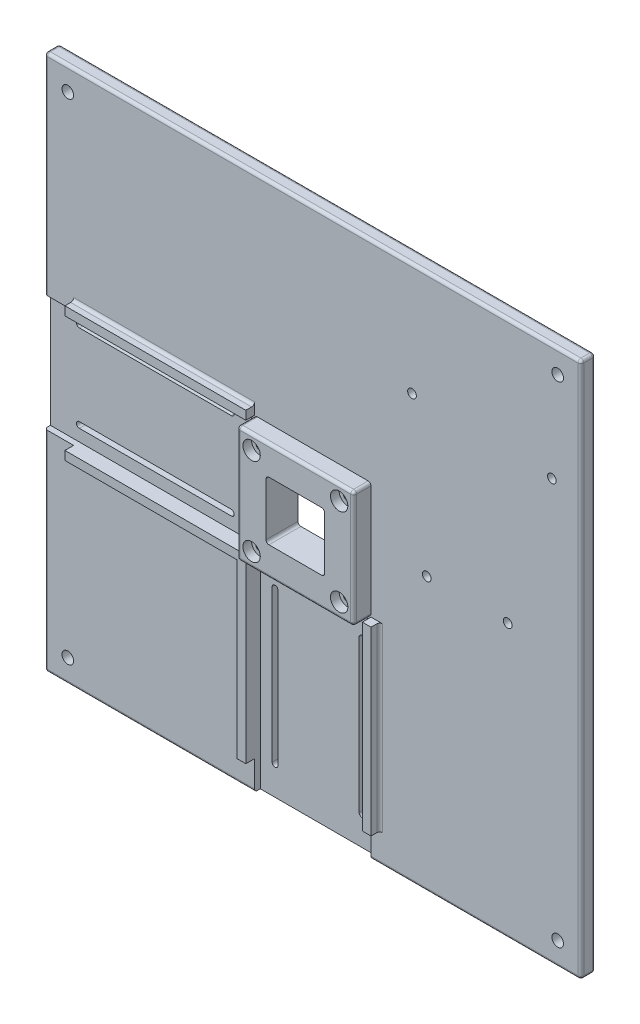
from build123d import *

# Parameters (mm, degrees)
ESQUISSE1_W                  = 185
ESQUISSE1_H                  = 185
BOSS_EXTRU_1_DEPTH           = 5
CONG_1_R                     = 1
ENL_V_MAT_EXTRU_4_REACH      = 7
ESQUISSE9_R                  = 2
ESQUISSE4_R                  = 1.6
ESQUISSE4_W                  = 20.2
ESQUISSE4_H                  = 20.2
ENL_V_MAT_EXTRU_5_DEPTH      = 1
ENL_V_MAT_EXTRU_5_DEPTH_BACK = 6
ESQUISSE11_W                 = 40.2
ESQUISSE11_H                 = 40.2
BOSS_EXTRU_3_DEPTH           = 6
CONG_2_R                     = 1
ESQUISSE12_R                 = 1.6
ENL_V_MAT_EXTRU_6_DEPTH      = 12
ESQUISSE13_R                 = 3
ENL_V_MAT_EXTRU_7_DEPTH      = 3
ENL_V_MAT_EXTRU_8_DEPTH      = 6
ESQUISSE15_W                 = 62.4
ESQUISSE15_H                 = 3
ESQUISSE15_W_2               = 3
ESQUISSE15_H_2               = 62.4
BOSS_EXTRU_4_DEPTH           = 3
CONG_3_R                     = 1
ESQUISSE20_R                 = 1.5
ENL_V_MAT_EXTRU_12_DEPTH     = 10
ESQUISSE21_W                 = 74.615624907
ESQUISSE21_H                 = 40.2
ENL_V_MAT_EXTRU_13_DEPTH     = 2
ESQUISSE22_W                 = 40.2
ESQUISSE22_H                 = 79.103769468
ENL_V_MAT_EXTRU_20_DEPTH     = 2


with BuildPart() as part:
    # Esquisse1 → Boss.-Extru.1 (new body)
    with BuildSketch(Plane.XY):
        Rectangle(ESQUISSE1_W, ESQUISSE1_H)
    extrude(amount=BOSS_EXTRU_1_DEPTH)

    # Congé1
    cong_1_edges = [part.edges().sort_by_distance(p)[0] for p in [
        (92.5, 0, 5),
        (0, 92.5, 5),
        (-92.5, 0, 5),
        (0, 92.5, 0),
        (92.5, 0, 0),
        (0, -92.5, 0),
        (-92.5, 0, 0),
        (-92.5, 92.5, 2.5),
        (92.5, 92.5, 2.5),
        (92.5, -92.5, 2.5),
        (-92.5, -92.5, 2.5),
        (0, -92.5, 5),
    ]]
    fillet(cong_1_edges, radius=CONG_1_R)

    # Esquisse9 → Enlèv. mat.-Extru.4 (cut, up to next)
    with BuildSketch(Plane(origin=(0, 0, 0), x_dir=(-1, 0, 0), z_dir=(0, 0, -1)), mode=Mode.PRIVATE) as enl_v_mat_extru_4_sk1:
        with Locations((-84.5, 84.5)):
            Circle(ESQUISSE9_R)
    enl_v_mat_extru_4_tool1 = extrude(enl_v_mat_extru_4_sk1.sketch, amount=-ENL_V_MAT_EXTRU_4_REACH, mode=Mode.PRIVATE) & part.part
    add(enl_v_mat_extru_4_tool1.solids().sort_by_distance((84.5, 84.5, 0))[0], mode=Mode.SUBTRACT)
    # Esquisse9 → Enlèv. mat.-Extru.4 (cut, up to next)
    with BuildSketch(Plane(origin=(0, 0, 0), x_dir=(-1, 0, 0), z_dir=(0, 0, -1)), mode=Mode.PRIVATE) as enl_v_mat_extru_4_sk2:
        with Locations((84.5, 84.5)):
            Circle(ESQUISSE9_R)
    enl_v_mat_extru_4_tool2 = extrude(enl_v_mat_extru_4_sk2.sketch, amount=-ENL_V_MAT_EXTRU_4_REACH, mode=Mode.PRIVATE) & part.part
    add(enl_v_mat_extru_4_tool2.solids().sort_by_distance((-84.5, 84.5, 0))[0], mode=Mode.SUBTRACT)
    # Esquisse9 → Enlèv. mat.-Extru.4 (cut, up to next)
    with BuildSketch(Plane(origin=(0, 0, 0), x_dir=(-1, 0, 0), z_dir=(0, 0, -1)), mode=Mode.PRIVATE) as enl_v_mat_extru_4_sk3:
        with Locations((84.5, -84.5)):
            Circle(ESQUISSE9_R)
    enl_v_mat_extru_4_tool3 = extrude(enl_v_mat_extru_4_sk3.sketch, amount=-ENL_V_MAT_EXTRU_4_REACH, mode=Mode.PRIVATE) & part.part
    add(enl_v_mat_extru_4_tool3.solids().sort_by_distance((-84.5, -84.5, 0))[0], mode=Mode.SUBTRACT)
    # Esquisse9 → Enlèv. mat.-Extru.4 (cut, up to next)
    with BuildSketch(Plane(origin=(0, 0, 0), x_dir=(-1, 0, 0), z_dir=(0, 0, -1)), mode=Mode.PRIVATE) as enl_v_mat_extru_4_sk4:
        with Locations((-84.5, -84.5)):
            Circle(ESQUISSE9_R)
    enl_v_mat_extru_4_tool4 = extrude(enl_v_mat_extru_4_sk4.sketch, amount=-ENL_V_MAT_EXTRU_4_REACH, mode=Mode.PRIVATE) & part.part
    add(enl_v_mat_extru_4_tool4.solids().sort_by_distance((84.5, -84.5, 0))[0], mode=Mode.SUBTRACT)

    # Esquisse4 → Enlèv. mat.-Extru.5 (cut, two sides)
    with BuildSketch(Plane.XY.offset(5)) as enl_v_mat_extru_5_sk:
        with Locations((-15.1, 15.1)):
            Circle(ESQUISSE4_R)
        with Locations((15.1, 15.1)):
            Circle(ESQUISSE4_R)
        with Locations((15.1, -15.1)):
            Circle(ESQUISSE4_R)
        with Locations((-15.1, -15.1)):
            Circle(ESQUISSE4_R)
        Rectangle(ESQUISSE4_W, ESQUISSE4_H)
    extrude(amount=ENL_V_MAT_EXTRU_5_DEPTH, mode=Mode.SUBTRACT)
    extrude(enl_v_mat_extru_5_sk.sketch, amount=-ENL_V_MAT_EXTRU_5_DEPTH_BACK, mode=Mode.SUBTRACT)

    # Esquisse11 → Boss.-Extru.3 (add)
    with BuildSketch(Plane.XY.offset(5)):
        Rectangle(ESQUISSE11_W, ESQUISSE11_H)
    extrude(amount=BOSS_EXTRU_3_DEPTH)

    # Congé2
    cong_2_edges = [part.edges().sort_by_distance(p)[0] for p in [
        (-20.1, -20.1, 8),
        (20.1, -20.1, 8),
        (0, 20.1, 11),
        (20.1, 20.1, 8),
        (-20.1, 0, 11),
        (-20.1, 20.1, 8),
        (0, -20.1, 11),
        (20.1, 0, 11),
        (-10.1, -10.1, 2.5),
        (-10.1, 10.1, 2.5),
        (10.1, 10.1, 2.5),
        (10.1, -10.1, 2.5),
    ]]
    fillet(cong_2_edges, radius=CONG_2_R)

    # Esquisse12 → Enlèv. mat.-Extru.6 (cut, through all)
    with BuildSketch(Plane.XY.offset(11)):
        with BuildLine():
            Line((10.1, -9.1), (10.1, 9.1))
            ThreePointArc((10.1, 9.1), (9.807106781, 9.807106781), (9.1, 10.1))
            Line((9.1, 10.1), (-9.1, 10.1))
            ThreePointArc((-9.1, 10.1), (-9.807106781, 9.807106781), (-10.1, 9.1))
            Line((-10.1, 9.1), (-10.1, -9.1))
            ThreePointArc((-10.1, -9.1), (-9.807106781, -9.807106781), (-9.1, -10.1))
            Line((-9.1, -10.1), (9.1, -10.1))
            ThreePointArc((9.1, -10.1), (9.807106781, -9.807106781), (10.1, -9.1))
        make_face()
        with Locations((15.1, 15.1)):
            Circle(ESQUISSE12_R)
        with Locations((-15.1, 15.1)):
            Circle(ESQUISSE12_R)
        with Locations((15.1, -15.1)):
            Circle(ESQUISSE12_R)
        with Locations((-15.1, -15.1)):
            Circle(ESQUISSE12_R)
    extrude(amount=-ENL_V_MAT_EXTRU_6_DEPTH, mode=Mode.SUBTRACT)

    # Esquisse13 → Enlèv. mat.-Extru.7 (cut)
    with BuildSketch(Plane.XY.offset(11)):
        with Locations((-15.1, 15.1)):
            Circle(ESQUISSE13_R)
        with Locations((15.1, 15.1)):
            Circle(ESQUISSE13_R)
        with Locations((15.1, -15.1)):
            Circle(ESQUISSE13_R)
        with Locations((-15.1, -15.1)):
            Circle(ESQUISSE13_R)
    extrude(amount=-ENL_V_MAT_EXTRU_7_DEPTH, mode=Mode.SUBTRACT)

    # Esquisse14 → Enlèv. mat.-Extru.8 (cut, through all)
    with BuildSketch(Plane.XY.offset(5)):
        with BuildLine():
            Line((-82.5, 16), (-30.1, 16))
            ThreePointArc((-30.1, 16), (-29.1, 15), (-30.1, 14))
            Line((-30.1, 14), (-82.5, 14))
            ThreePointArc((-82.5, 14), (-83.5, 15), (-82.5, 16))
        make_face()
        with BuildLine():
            Line((-30.1, -16), (-82.5, -16))
            ThreePointArc((-82.5, -16), (-83.5, -15), (-82.5, -14))
            Line((-82.5, -14), (-30.1, -14))
            ThreePointArc((-30.1, -14), (-29.1, -15), (-30.1, -16))
        make_face()
        with BuildLine():
            Line((16, -30.1), (16, -82.5))
            ThreePointArc((16, -82.5), (15, -83.5), (14, -82.5))
            Line((14, -82.5), (14, -30.1))
            ThreePointArc((14, -30.1), (15, -29.1), (16, -30.1))
        make_face()
        with BuildLine():
            Line((-16, -82.5), (-16, -30.1))
            ThreePointArc((-16, -30.1), (-15, -29.1), (-14, -30.1))
            Line((-14, -30.1), (-14, -82.5))
            ThreePointArc((-14, -82.5), (-15, -83.5), (-16, -82.5))
        make_face()
    extrude(amount=-ENL_V_MAT_EXTRU_8_DEPTH, mode=Mode.SUBTRACT)

    # Esquisse15 → Boss.-Extru.4 (add)
    with BuildSketch(Plane.XY.offset(5)):
        Polygon((-20.1, -20.1), (-20.1, -82.5), (-23.1, -82.5), (-23.1, -23.1), (-82.5, -23.1), (-82.5, -20.1), align=None)
        with Locations((-51.3, 21.6)):
            Rectangle(ESQUISSE15_W, ESQUISSE15_H)
        with Locations((21.6, -51.3)):
            Rectangle(ESQUISSE15_W_2, ESQUISSE15_H_2)
    extrude(amount=BOSS_EXTRU_4_DEPTH)

    # Congé3
    cong_3_edges = [part.edges().sort_by_distance(p)[0] for p in [
        (-51.3, 23.1, 5),
        (-52.8, -23.1, 5),
        (-23.1, -52.8, 5),
        (23.1, -51.3, 5),
    ]]
    fillet(cong_3_edges, radius=CONG_3_R)

    # Esquisse20 → Enlèv. mat.-Extru.12 (cut)
    with BuildSketch(Plane.XY.offset(5)):
        with Locations((39.32, 1.7)):
            Circle(ESQUISSE20_R)
        with Locations((34.24, 53.77)):
            Circle(ESQUISSE20_R)
        with Locations((82.5, 52.5)):
            Circle(ESQUISSE20_R)
        with Locations((67.26, 1.7)):
            Circle(ESQUISSE20_R)
    extrude(amount=-ENL_V_MAT_EXTRU_12_DEPTH, mode=Mode.SUBTRACT)

    # Esquisse21 → Enlèv. mat.-Extru.13 (cut)
    with BuildSketch(Plane.XY.offset(5)):
        with Locations((-58.407812454, 0)):
            Rectangle(ESQUISSE21_W, ESQUISSE21_H)
    extrude(amount=-ENL_V_MAT_EXTRU_13_DEPTH, mode=Mode.SUBTRACT)

    # Esquisse22 → Enlèv. mat.-Extru.20 (cut)
    with BuildSketch(Plane.XY.offset(5)):
        with Locations((0, -60.651884734)):
            Rectangle(ESQUISSE22_W, ESQUISSE22_H)
    extrude(amount=-ENL_V_MAT_EXTRU_20_DEPTH, mode=Mode.SUBTRACT)


solid = part.part
